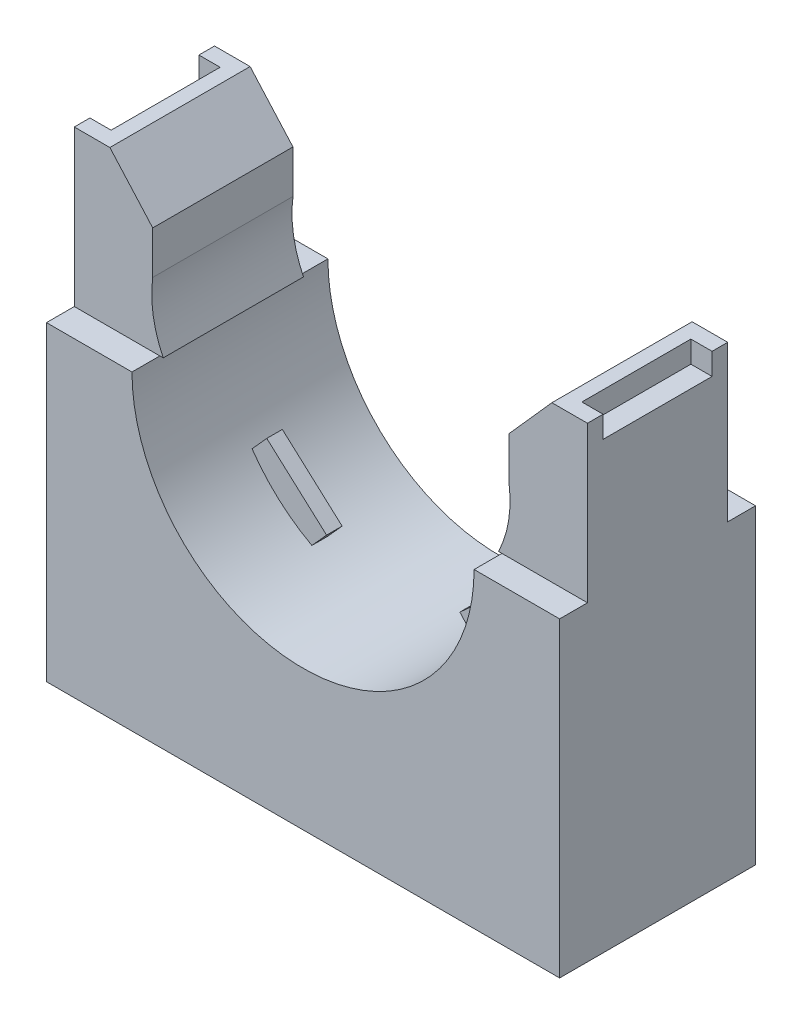
from build123d import *

# Parameters (mm, degrees)
SKETCH1_W               = 41.91
SKETCH1_H               = 38.1
EXTRUDE1_DEPTH          = 16.002
CUT_EXTRUDE1_DEPTH      = 17.002
SKETCH3_W               = 2.27457
SKETCH3_H               = 12.7
CUT_EXTRUDE2_DEPTH      = 21.955
CUT_EXTRUDE2_DEPTH_BACK = 21.955
SKETCH4_W               = 40.3225
SKETCH4_H               = 14.4145
CUT_EXTRUDE3_DEPTH      = 0.254
SKETCH5_W               = 1.731382872
SKETCH5_H               = 8.90143
CUT_EXTRUDE4_DEPTH      = 1.778
EXTRUDE2_DEPTH          = 0.635


with BuildPart() as part:
    # Sketch1 → Extrude1 (new body)
    with BuildSketch(Plane.XY):
        Rectangle(SKETCH1_W, SKETCH1_H)
    extrude(amount=EXTRUDE1_DEPTH)

    # Sketch2 → Cut-Extrude1 (cut, through all)
    with BuildSketch(Plane.XY.offset(16.002)):
        with BuildLine():
            Line((-13.97, 6.35), (-13.6906, 6.35))
            ThreePointArc((-13.6906, 6.35), (-14.51249132, 8.917230674), (-14.5494375, 11.6125625))
            Line((-14.5494375, 11.6125625), (-14.5494375, 15.113))
            Line((-14.5494375, 15.113), (-18.049875, 19.05))
            Line((-18.049875, 19.05), (18.049875, 19.05))
            Line((18.049875, 19.05), (14.5494375, 15.113))
            Line((14.5494375, 15.113), (14.5494375, 11.6125625))
            ThreePointArc((14.5494375, 11.6125625), (14.51249132, 8.917230674), (13.6906, 6.35))
            Line((13.6906, 6.35), (13.97, 6.35))
            ThreePointArc((13.97, 6.35), (0, -7.62), (-13.97, 6.35))
        make_face()
    extrude(amount=-CUT_EXTRUDE1_DEPTH, mode=Mode.SUBTRACT)

    # Sketch3 → Cut-Extrude2 (cut, two sides)
    with BuildSketch(Plane(origin=(0, 0, 0), x_dir=(0, 0, -1), z_dir=(1, 0, 0))) as cut_extrude2_sk:
        with Locations((-14.864715, 12.7)):
            Rectangle(SKETCH3_W, SKETCH3_H)
        with Locations((-1.137285, 12.7)):
            Rectangle(SKETCH3_W, SKETCH3_H)
    extrude(amount=CUT_EXTRUDE2_DEPTH, mode=Mode.SUBTRACT)
    extrude(cut_extrude2_sk.sketch, amount=-CUT_EXTRUDE2_DEPTH_BACK, mode=Mode.SUBTRACT)

    # Sketch4 → Cut-Extrude3 (cut)
    with BuildSketch(Plane.XZ.offset(19.05)):
        with Locations((0, 8.001)):
            Rectangle(SKETCH4_W, SKETCH4_H)
    extrude(amount=-CUT_EXTRUDE3_DEPTH, mode=Mode.SUBTRACT)

    # Sketch5 → Cut-Extrude4 (cut)
    with BuildSketch(Plane(origin=(0, 19.05, 0), x_dir=(1, 0, 0), z_dir=(0, 1, 0))):
        with Locations((-20.089308564, -8.001)):
            Rectangle(SKETCH5_W, SKETCH5_H)
        with Locations((20.089308564, -8.001)):
            Rectangle(SKETCH5_W, SKETCH5_H)
    extrude(amount=-CUT_EXTRUDE4_DEPTH, mode=Mode.SUBTRACT)

    # Sketch6 → Cut-Revolve1 (revolve, cut)
    with BuildSketch(Plane(origin=(0, 0, 8.001), x_dir=(-1, 0, 0), z_dir=(0, 0, -1)), mode=Mode.PRIVATE) as cut_revolve1_sk:
        Polygon((3.25, -18.796), (0, -18.796), (0, -12.296), (5.842, -12.296), (5.842, -15.546), (3.25, -15.546), align=None)
    revolve(cut_revolve1_sk.sketch.rotate(Axis((0, 0, 8.001), (0, -1, 0)), 270), axis=Axis((0, 0, 8.001), (0, -1, 0)), mode=Mode.SUBTRACT)  # turned: the seam where the file's is

    # Sketch7 → Extrude2 (add, symmetric)
    with BuildSketch(Plane(origin=(0, 0, 8.001), x_dir=(-1, 0, 0), z_dir=(0, 0, -1))):
        with BuildLine():
            Line((5.443056808, -4.606163762), (10.327190387, -0.208470134))
            Line((10.327190387, -0.208470134), (11.527527053, -1.541579058))
            ThreePointArc((11.527527053, -1.541579058), (9.347754571, -4.031733212), (6.643393474, -5.939272686))
            Line((6.643393474, -5.939272686), (5.443056808, -4.606163762))
        make_face()
        with BuildLine():
            Line((-5.443056808, -4.606163762), (-6.643393474, -5.939272686))
            ThreePointArc((-6.643393474, -5.939272686), (-9.347754571, -4.031733212), (-11.527527053, -1.541579058))
            Line((-11.527527053, -1.541579058), (-10.327190387, -0.208470134))
            Line((-10.327190387, -0.208470134), (-5.443056808, -4.606163762))
        make_face()
    extrude(amount=EXTRUDE2_DEPTH, both=True)


solid = part.part
